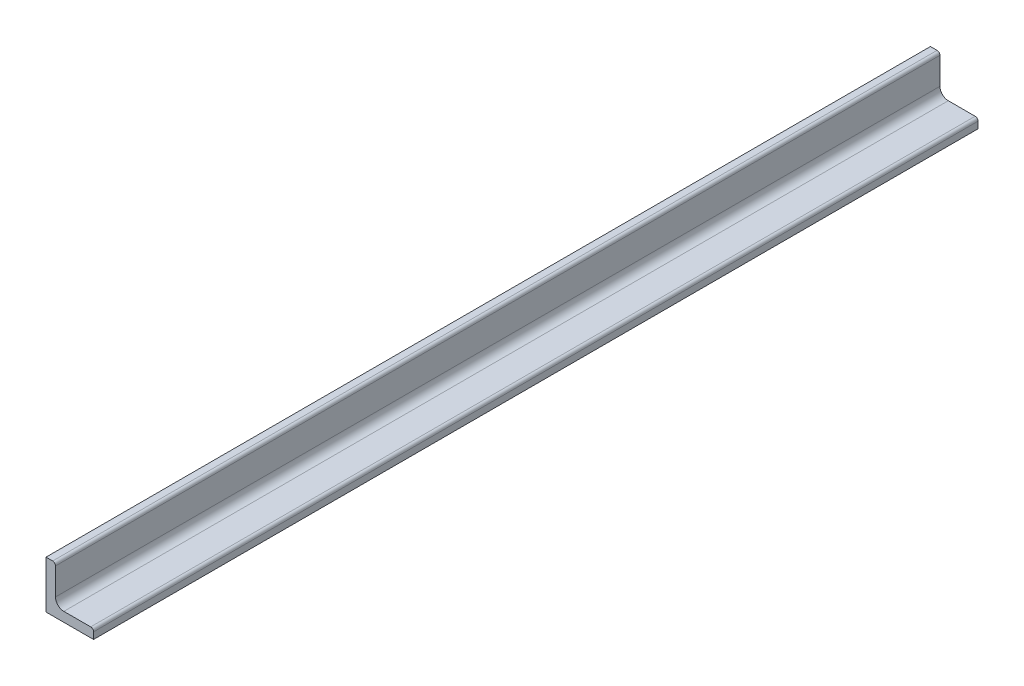
from build123d import *

# Parameters (mm, degrees)
EXTRUDE_1_DEPTH = 372


with BuildPart() as part:
    # Эскиз1 → Бобышка-Вытянуть1 (new body)
    with BuildSketch(Plane.XY):
        with BuildLine():
            Line((-7.5, 12.5), (-7.5, -7.5))
            Line((-7.5, -7.5), (12.5, -7.5))
            Line((12.5, -7.5), (12.5, -4.7))
            ThreePointArc((12.5, -4.7), (12.148528137, -3.851471863), (11.3, -3.5))
            Line((11.3, -3.5), (0, -3.5))
            ThreePointArc((0, -3.5), (-2.474873734, -2.474873734), (-3.5, 0))
            Line((-3.5, 0), (-3.5, 11.3))
            ThreePointArc((-3.5, 11.3), (-3.851471863, 12.148528137), (-4.7, 12.5))
            Line((-4.7, 12.5), (-7.5, 12.5))
        make_face()
    extrude(amount=EXTRUDE_1_DEPTH)


solid = part.part
